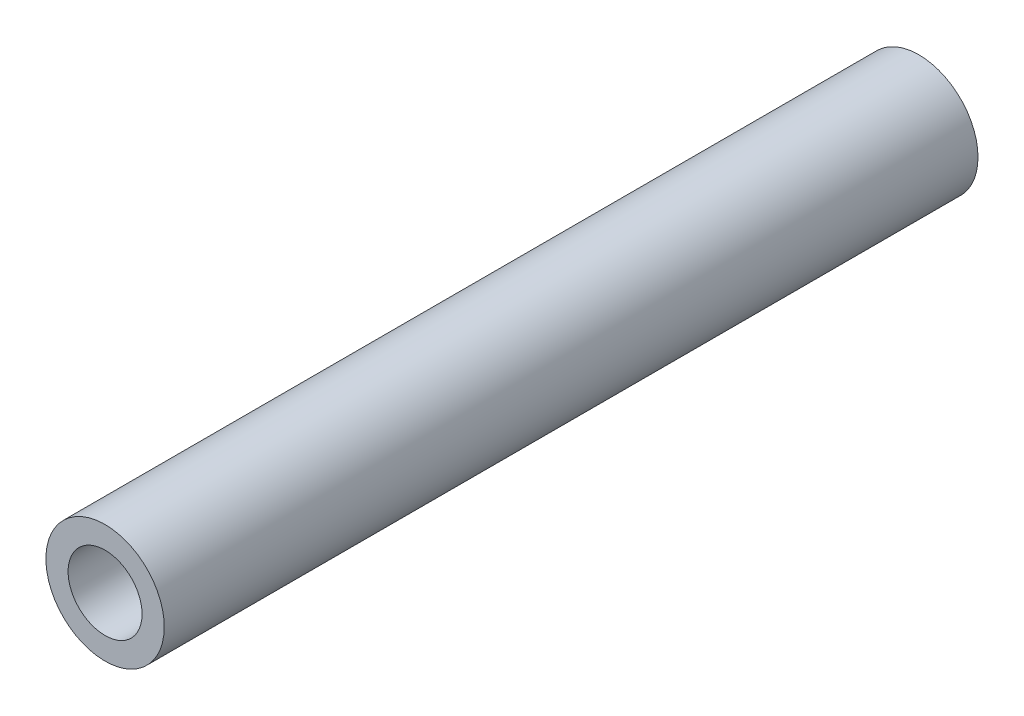
from build123d import *

# Parameters (mm, degrees)
SKETCH_1_R      = 1.6
SKETCH_1_R_2    = 1
EXTRUDE_1_DEPTH = 22


with BuildPart() as part:
    # 草图1 → 凸台-拉伸1 (new body)
    with BuildSketch(Plane.XY):
        Circle(SKETCH_1_R)
        Circle(SKETCH_1_R_2, mode=Mode.SUBTRACT)
    extrude(amount=EXTRUDE_1_DEPTH)


solid = part.part
